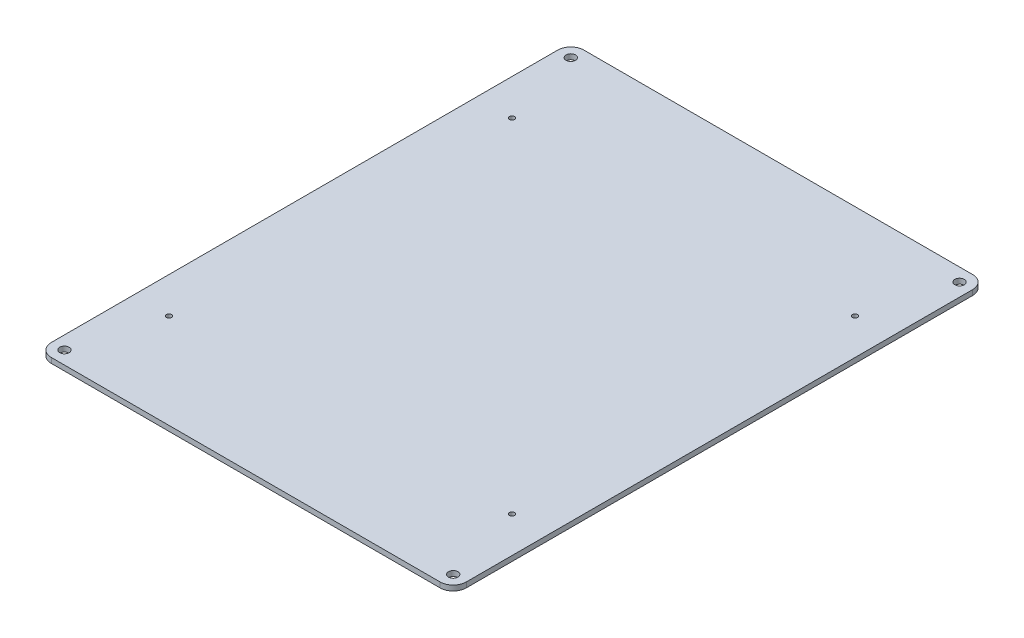
from build123d import *

# Parameters (mm, degrees)
SKETCH1_W                  = 254
SKETCH1_H                  = 326
BOSS_EXTRUDE1_DEPTH        = 3.175
M2_5_CLEARANCE_HOLE1_D     = 3.1
M2_5_CLEARANCE_HOLE1_DEPTH = 11.938
M2_5_CLEARANCE_HOLE1_TIP   = 0.931333959
M5_CLEARANCE_HOLE1_D       = 5.8
M5_CLEARANCE_HOLE1_DEPTH   = 11.938
M5_CLEARANCE_HOLE1_TIP     = 1.742495795
FILLET1_R                  = 8


with BuildPart() as part:
    # Sketch1 → Boss-Extrude1 (new body)
    with BuildSketch(Plane(origin=(0, 0, 0), x_dir=(1, 0, 0), z_dir=(0, 1, 0))):
        Rectangle(SKETCH1_W, SKETCH1_H)
    extrude(amount=BOSS_EXTRUDE1_DEPTH)

    # M2.5 Clearance Hole1
    with Locations(Plane(origin=(-105, 3.175, 105), x_dir=(0, 0, 1), z_dir=(0, 1, 0))):
        with Locations((0, 0), (-210, 0), (-210, 210), (0, 210)):
            Hole(M2_5_CLEARANCE_HOLE1_D / 2, depth=M2_5_CLEARANCE_HOLE1_DEPTH)
            with Locations((0, 0, -(M2_5_CLEARANCE_HOLE1_DEPTH + M2_5_CLEARANCE_HOLE1_TIP / 2))):  # 118° drill point
                Cone(0, M2_5_CLEARANCE_HOLE1_D / 2, M2_5_CLEARANCE_HOLE1_TIP, mode=Mode.SUBTRACT)

    # M5 Clearance Hole1
    with Locations(Plane(origin=(0, 3.175, 0), x_dir=(1, 0, 0), z_dir=(0, 1, 0))):
        with Locations((-119, 155), (119, 155), (119, -155), (-119, -155)):
            Hole(M5_CLEARANCE_HOLE1_D / 2, depth=M5_CLEARANCE_HOLE1_DEPTH)
            with Locations((0, 0, -(M5_CLEARANCE_HOLE1_DEPTH + M5_CLEARANCE_HOLE1_TIP / 2))):  # 118° drill point
                Cone(0, M5_CLEARANCE_HOLE1_D / 2, M5_CLEARANCE_HOLE1_TIP, mode=Mode.SUBTRACT)

    # Fillet1
    fillet1_edges = [part.edges().sort_by_distance(p)[0] for p in [
        (-127, 1.5875, -163),
        (127, 1.5875, -163),
        (127, 1.5875, 163),
        (-127, 1.5875, 163),
    ]]
    fillet(fillet1_edges, radius=FILLET1_R)


solid = part.part
